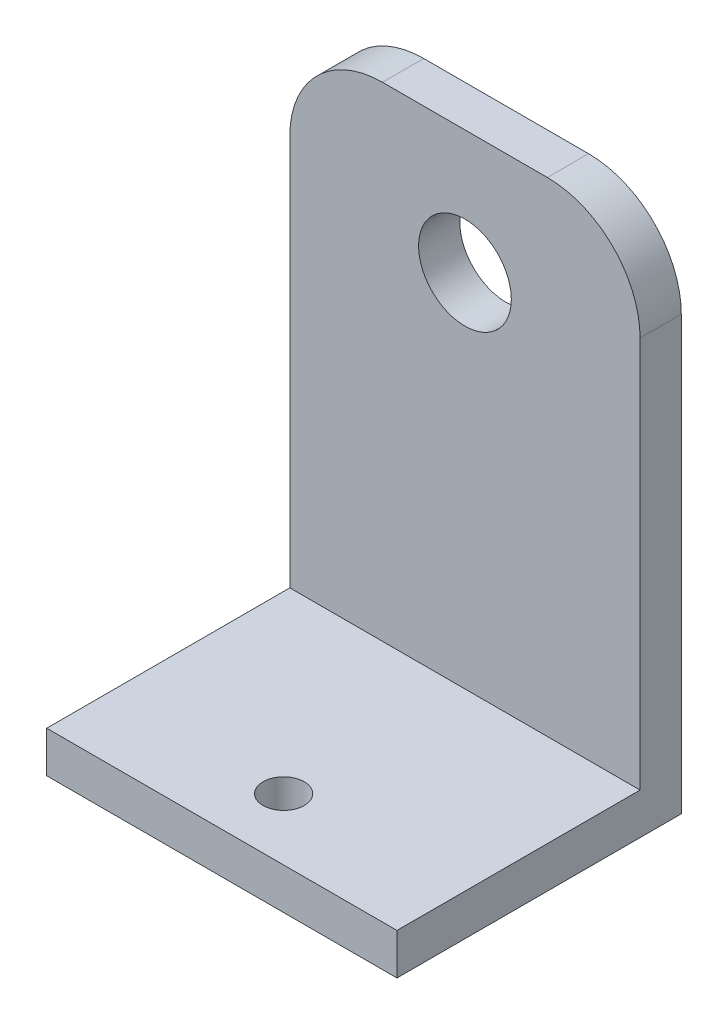
from build123d import *

# Parameters (mm, degrees)
SKETCH2_W           = 34
SKETCH2_H           = 27.6
SKETCH2_R           = 2
BOSS_EXTRUDE1_DEPTH = 4
SKETCH3_W           = 34
SKETCH3_H           = 4
BOSS_EXTRUDE2_DEPTH = 47
FILLET1_R           = 9
SKETCH4_R           = 4.5
CUT_EXTRUDE1_DEPTH  = 5


with BuildPart() as part:
    # Sketch2 → Boss-Extrude1 (new body)
    with BuildSketch(Plane(origin=(0, 0, 0), x_dir=(1, 0, 0), z_dir=(0, 1, 0))):
        Rectangle(SKETCH2_W, SKETCH2_H)
        with Locations((0, -7.8)):
            Circle(SKETCH2_R, mode=Mode.SUBTRACT)
    extrude(amount=BOSS_EXTRUDE1_DEPTH)

    # Sketch3 → Boss-Extrude2 (add)
    with BuildSketch(Plane(origin=(0, 4, 0), x_dir=(1, 0, 0), z_dir=(0, 1, 0))):
        with Locations((0, 11.8)):
            Rectangle(SKETCH3_W, SKETCH3_H)
    extrude(amount=BOSS_EXTRUDE2_DEPTH)

    # Fillet1
    fillet1_edges = [part.edges().sort_by_distance(p)[0] for p in [
        (-17, 51, -11.8),
        (17, 51, -11.8),
    ]]
    fillet(fillet1_edges, radius=FILLET1_R)

    # Sketch4 → Cut-Extrude1 (cut, through all)
    with BuildSketch(Plane.XY.offset(-9.8)):
        with Locations((0, 39)):
            Circle(SKETCH4_R)
    extrude(amount=-CUT_EXTRUDE1_DEPTH, mode=Mode.SUBTRACT)


solid = part.part
